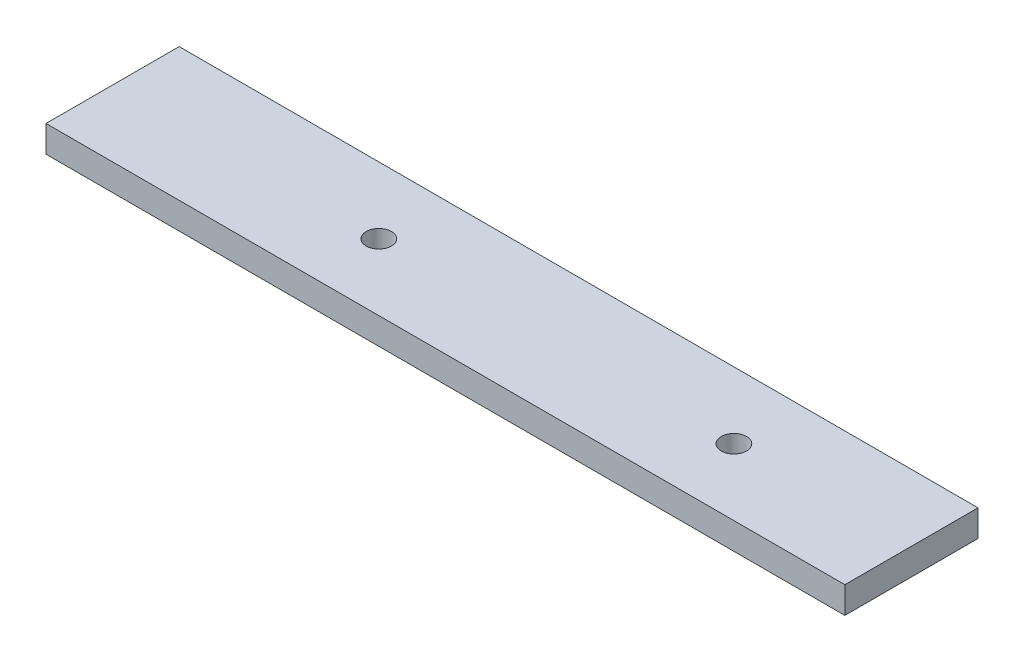
from build123d import *

# Parameters (mm, degrees)
SKETCH1_W           = 100
SKETCH1_H           = 15
BOSS_EXTRUDE1_DEPTH = 3
SKETCH2_R           = 1
CUT_EXTRUDE1_DEPTH  = 10
SKETCH3_R           = 2.5
CUT_EXTRUDE2_DEPTH  = 10
CUT_EXTRUDE3_DEPTH  = 10
FILLET1_R           = 5
FILLET2_R           = 1
SKETCH7_W           = 15
SKETCH7_H           = 3
BOSS_EXTRUDE2_DEPTH = 20
SKETCH8_W           = 41.116503549
SKETCH8_H           = 15
CUT_EXTRUDE6_DEPTH  = 20
SKETCH9_R           = 1.425
CUT_EXTRUDE7_DEPTH  = 20


with BuildPart() as part:
    # Sketch1 → Boss-Extrude1 (new body)
    with BuildSketch(Plane(origin=(0, 0, 0), x_dir=(1, 0, 0), z_dir=(0, 1, 0))):
        Rectangle(SKETCH1_W, SKETCH1_H)
    extrude(amount=BOSS_EXTRUDE1_DEPTH)

    # Sketch2 → Cut-Extrude1 (cut)
    with BuildSketch(Plane(origin=(0, 3, 0), x_dir=(1, 0, 0), z_dir=(0, 1, 0))):
        with Locations((-28.87, 0)):
            Circle(SKETCH2_R)
        with Locations((-42, 0)):
            Circle(SKETCH2_R)
    extrude(amount=-CUT_EXTRUDE1_DEPTH, mode=Mode.SUBTRACT)

    # Sketch3 → Cut-Extrude2 (cut)
    with BuildSketch(Plane.XZ):
        with Locations((-35.434103263, -0.006545742)):
            Circle(SKETCH3_R)
    extrude(amount=-CUT_EXTRUDE2_DEPTH, mode=Mode.SUBTRACT)

    # Sketch4 → Cut-Extrude3 (cut)
    with BuildSketch(Plane(origin=(0, 0, 0), x_dir=(-1, 0, 0), z_dir=(0, -1, 0))):
        with BuildLine():
            Line((50, 1.885031535), (50, 7.5))
            Line((50, 7.5), (39.062958866, 7.5))
            Line((39.062958866, 7.5), (41.762759664, 3.577599022))
            ThreePointArc((41.762759664, 3.577599022), (42.595166406, 2.79306797), (43.676751147, 2.42082557))
            Line((43.676751147, 2.42082557), (50, 1.885031535))
        make_face()
    cut_extrude3 = extrude(amount=-CUT_EXTRUDE3_DEPTH, mode=Mode.SUBTRACT)

    # Mirror1: Cut-Extrude3 across plane
    add(cut_extrude3.mirror(Plane.XY), mode=Mode.SUBTRACT)

    # Fillet1
    fillet1_edges = [part.edges().sort_by_distance(p)[0] for p in [
        (-39.062958866, 1.5, -7.5),
        (-39.062958866, 1.5, 7.5),
    ]]
    fillet(fillet1_edges, radius=FILLET1_R)

    # Fillet2
    fillet2_edges = [part.edges().sort_by_distance(p)[0] for p in [
        (-50, 1.5, -1.885031535),
        (-50, 1.5, 1.885031535),
    ]]
    fillet(fillet2_edges, radius=FILLET2_R)

    # Sketch7 → Boss-Extrude2 (add)
    with BuildSketch(Plane(origin=(50, 0, 0), x_dir=(0, 0, -1), z_dir=(1, 0, 0))):
        with Locations((0, 1.5)):
            Rectangle(SKETCH7_W, SKETCH7_H)
    extrude(amount=BOSS_EXTRUDE2_DEPTH)

    # Sketch8 → Cut-Extrude6 (cut)
    with BuildSketch(Plane(origin=(0, 3, 0), x_dir=(1, 0, 0), z_dir=(0, 1, 0))):
        with Locations((-40.558251775, 0)):
            Rectangle(SKETCH8_W, SKETCH8_H)
    extrude(amount=-CUT_EXTRUDE6_DEPTH, mode=Mode.SUBTRACT)

    # Sketch9 → Cut-Extrude7 (cut)
    with BuildSketch(Plane(origin=(0, 3, 0), x_dir=(1, 0, 0), z_dir=(0, 1, 0))):
        with Locations((50, 0)):
            Circle(SKETCH9_R)
        with Locations((10, 0)):
            Circle(SKETCH9_R)
    extrude(amount=-CUT_EXTRUDE7_DEPTH, mode=Mode.SUBTRACT)


solid = part.part
